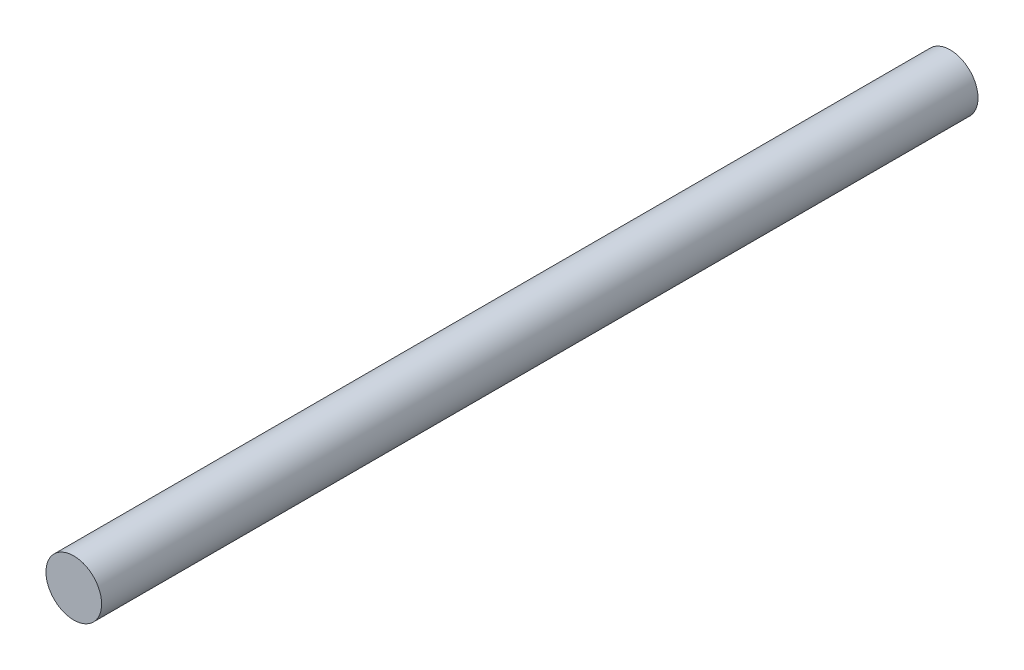
from build123d import *

# Parameters (mm, degrees)
SKETCH1_R           = 3.175
BOSS_EXTRUDE1_DEPTH = 100


with BuildPart() as part:
    # Sketch1 → Boss-Extrude1 (new body)
    with BuildSketch(Plane.XY):
        Circle(SKETCH1_R)
    extrude(amount=BOSS_EXTRUDE1_DEPTH)


solid = part.part
